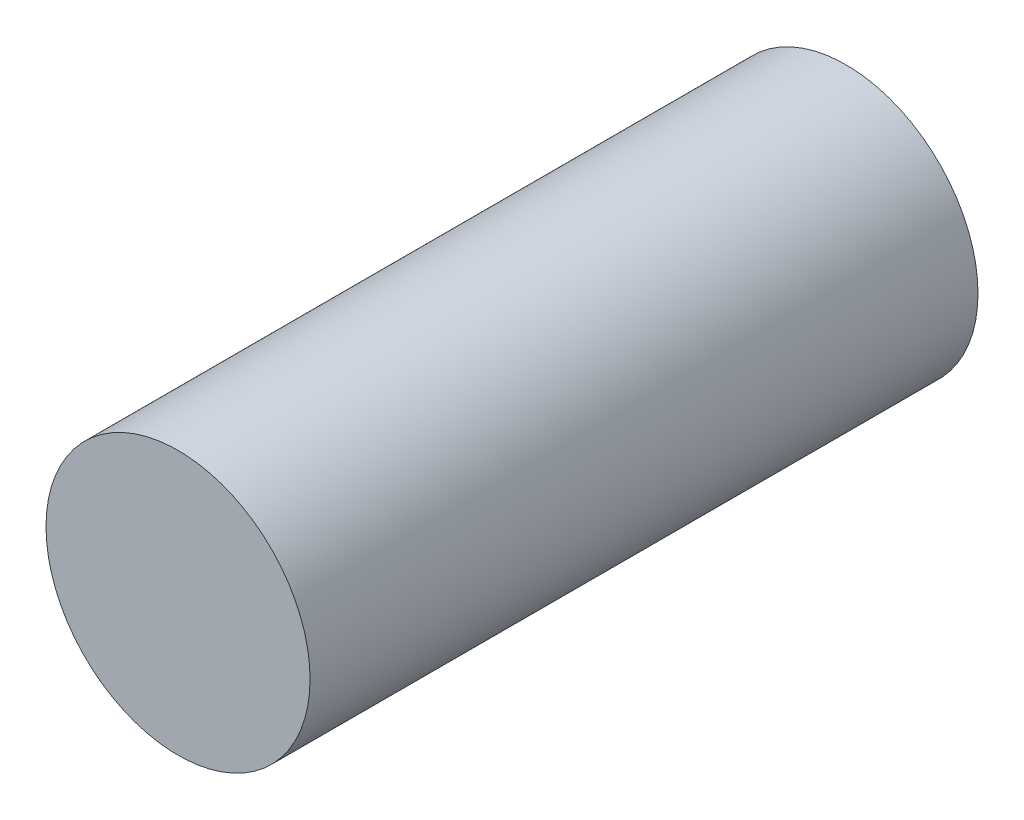
from build123d import *

# Parameters (mm, degrees)
MAIN_SKETCH_R        = 8.5
MAIN_EXTRUSION_DEPTH = 43


with BuildPart() as part:
    # Main-Sketch → Main-Extrusion (new body)
    with BuildSketch(Plane.XY):
        Circle(MAIN_SKETCH_R)
    extrude(amount=MAIN_EXTRUSION_DEPTH)


solid = part.part
